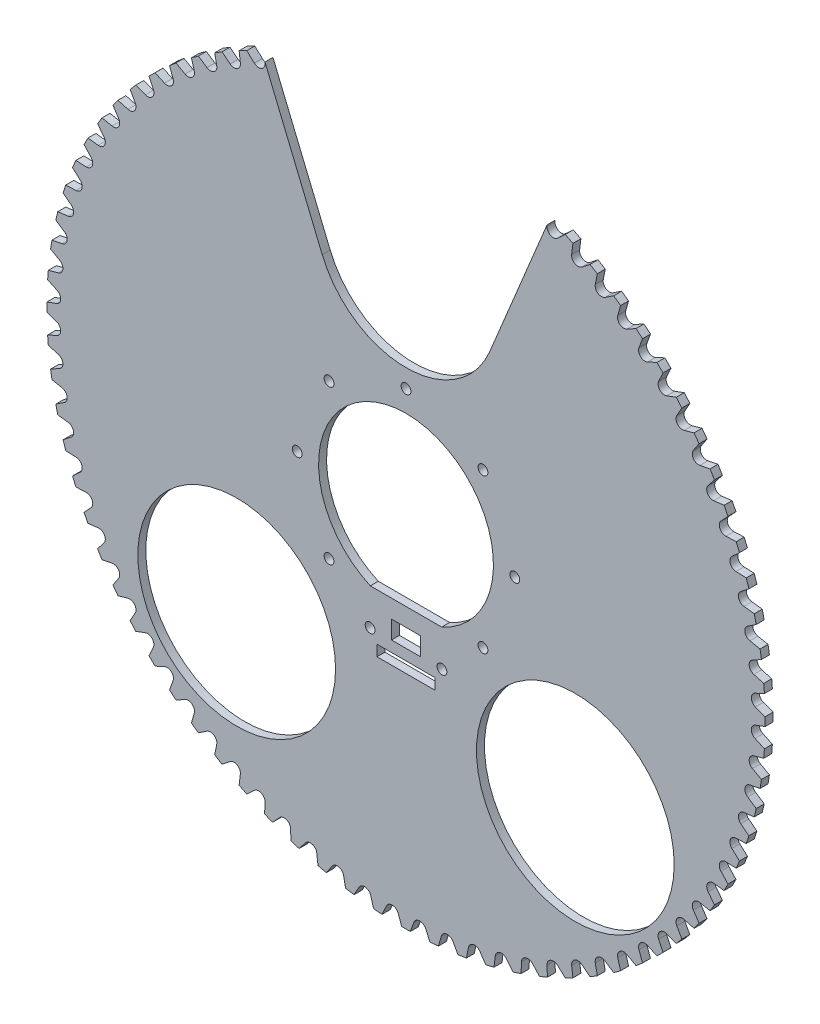
from build123d import *

# Parameters (mm, degrees)
ESQUISSE1_R        = 99
MAIN_DEPTH         = 2.2
ESQUISSE2_R        = 27.25
ESQUISSE2_R_2      = 1.35
ESQUISSE2_W        = 8
ESQUISSE2_H        = 5
ESQUISSE2_W_2      = 16
ESQUISSE2_H_2      = 3
HOLES_DEPTH        = 1
HOLES_DEPTH_BACK   = 3.2
SKETCH1_R          = 1.35
FIXINGHOLES_DEPTH  = 3.2
CIRPATTERN1_COUNT  = 6
CIRPATTERN1_ANGLE  = 225
CUT_EXTRUDE3_DEPTH = 3.2
CIRPATTERN2_COUNT  = 80
CIRPATTERN3_COUNT  = 2
CIRPATTERN3_ANGLE  = 45


with BuildPart() as part:
    # Esquisse1 → Main (new body)
    with BuildSketch(Plane.XY):
        Circle(ESQUISSE1_R)
        with BuildLine():
            Line((-9.839207285, -22), (9.839207285, -22))
            ThreePointArc((9.839207285, -22), (0, 24.1), (-9.839207285, -22))
        make_face(mode=Mode.SUBTRACT)
    extrude(amount=MAIN_DEPTH)

    # Esquisse2 → Holes (cut, two sides)
    with BuildSketch(Plane.XY.offset(2.2)) as holes_sk:
        with Locations((-46.669047558, -46.669047558)):
            Circle(ESQUISSE2_R)
        with Locations((46.669047558, -46.669047558)):
            Circle(ESQUISSE2_R)
        with Locations((-9.9, -32)):
            Circle(ESQUISSE2_R_2)
        with Locations((9.9, -32)):
            Circle(ESQUISSE2_R_2)
        with BuildLine():
            Line((-23.096988313, 50.432914191), (-39.76140845, 90.664383294))
            ThreePointArc((-39.76140845, 90.664383294), (0, 99), (39.76140845, 90.664383294))
            Line((39.76140845, 90.664383294), (23.096988313, 50.432914191))
            ThreePointArc((23.096988313, 50.432914191), (0, 35), (-23.096988313, 50.432914191))
        make_face()
        with Locations((0, -29.5)):
            Rectangle(ESQUISSE2_W, ESQUISSE2_H)
        with Locations((0, -36.5)):
            Rectangle(ESQUISSE2_W_2, ESQUISSE2_H_2)
    extrude(amount=HOLES_DEPTH, mode=Mode.SUBTRACT)
    extrude(holes_sk.sketch, amount=-HOLES_DEPTH_BACK, mode=Mode.SUBTRACT)

    # Sketch1 → FixingHoles (cut, through all)
    with BuildSketch(Plane.XY.offset(2.2)):
        with Locations((30, 0)):
            Circle(SKETCH1_R)
    fixingholes = extrude(amount=-FIXINGHOLES_DEPTH, mode=Mode.SUBTRACT)

    # CirPattern1: FixingHoles ×6 about axis
    cirpattern1_axis = Axis((0, 0, 0), (0, 0, 1))
    for i in range(1, CIRPATTERN1_COUNT):
        add(fixingholes.rotate(cirpattern1_axis, i * CIRPATTERN1_ANGLE / (CIRPATTERN1_COUNT - 1)), mode=Mode.SUBTRACT)

    # Sketch2 → Cut-Extrude3 (cut, through all)
    with BuildSketch(Plane.XY.offset(2.2)):
        with BuildLine():
            Line((96.192561975, 5.397452683), (98.780392054, 6.59045869))
            ThreePointArc((98.780392054, 6.59045869), (98.923674588, 3.88672176), (98.9929665, 1.180077731))
            Line((98.9929665, 1.180077731), (96.319511665, 2.166367291))
            ThreePointArc((96.319511665, 2.166367291), (95.176565702, 3.739497451), (96.192561975, 5.397452683))
        make_face()
    cut_extrude3 = extrude(amount=-CUT_EXTRUDE3_DEPTH, mode=Mode.SUBTRACT)

    # CirPattern2: Cut-Extrude3 ×80 about axis
    cirpattern2_axis = Axis((0, 0, 0), (0, 0, 1))
    for i in range(1, CIRPATTERN2_COUNT):
        add(cut_extrude3.rotate(cirpattern2_axis, i * 360 / CIRPATTERN2_COUNT), mode=Mode.SUBTRACT)

    # CirPattern3: FixingHoles ×2 about axis
    cirpattern3_axis = Axis((0, 0, 2.625), (0, 0, -1))
    for i in range(1, CIRPATTERN3_COUNT):
        add(fixingholes.rotate(cirpattern3_axis, i * CIRPATTERN3_ANGLE / (CIRPATTERN3_COUNT - 1)), mode=Mode.SUBTRACT)


solid = part.part
